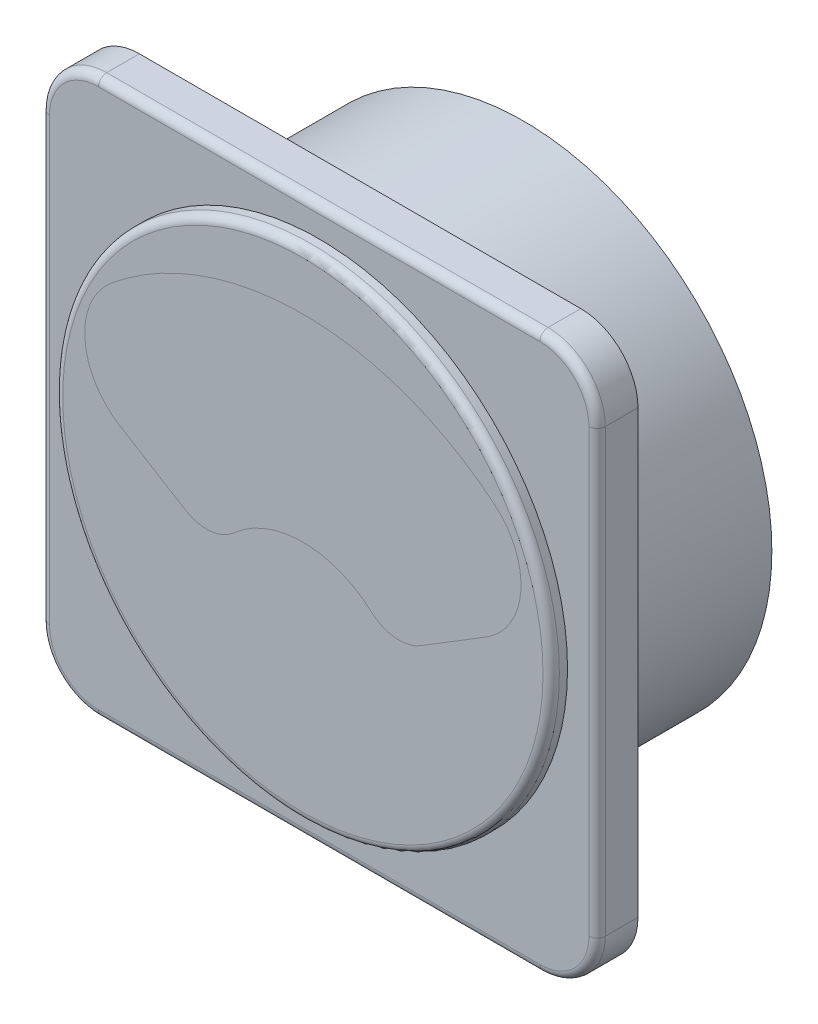
from build123d import *

# Parameters (mm, degrees)
SKETCH1_R           = 30.382618143
BOSS_EXTRUDE1_DEPTH = 20
SKETCH2_R           = 27.5
BOSS_EXTRUDE2_DEPTH = 5
SKETCH3_R           = 30.382618143
BOSS_EXTRUDE3_DEPTH = 2
BOSS_EXTRUDE4_DEPTH = 1
BOSS_EXTRUDE5_DEPTH = 1
FILLET1_R           = 1
FILLET2_R           = 1


with BuildPart() as part:
    # Sketch1 → Boss-Extrude1 (new body)
    with BuildSketch(Plane.XY):
        Circle(SKETCH1_R)
    extrude(amount=-BOSS_EXTRUDE1_DEPTH)


with BuildPart() as body_2:
    # Sketch2 → Boss-Extrude2 (new body)
    with BuildSketch(Plane.XY):
        with BuildLine():
            Line((-27, -34), (27, -34))
            ThreePointArc((27, -34), (31.949747468, -31.949747468), (34, -27))
            Line((34, -27), (34, 27))
            ThreePointArc((34, 27), (31.949747468, 31.949747468), (27, 34))
            Line((27, 34), (-27, 34))
            ThreePointArc((-27, 34), (-31.949747468, 31.949747468), (-34, 27))
            Line((-34, 27), (-34, -27))
            ThreePointArc((-34, -27), (-31.949747468, -31.949747468), (-27, -34))
        make_face()
        Circle(SKETCH2_R, mode=Mode.SUBTRACT)
    extrude(amount=BOSS_EXTRUDE2_DEPTH)

    # Fillet2
    fillet2_edges = [body_2.edges().sort_by_distance(p)[0] for p in [
        (-31.949747468, -31.949747468, 5),
        (0, -34, 5),
        (31.949747468, -31.949747468, 5),
        (34, 0, 5),
        (31.949747468, 31.949747468, 5),
        (0, 34, 5),
        (-31.949747468, 31.949747468, 5),
        (-34, 0, 5),
    ]]
    fillet(fillet2_edges, radius=FILLET2_R)


with BuildPart() as body_3:
    # Sketch3 → Boss-Extrude3 (new body)
    with BuildSketch(Plane.XY.offset(5)):
        Circle(SKETCH3_R)
        with BuildLine():
            Line((14.390861658, -4.518418841), (22.394682178, 0.392456244))
            ThreePointArc((22.394682178, 0.392456244), (26.6658507, 7.433621582), (23.419848559, 15.002264787))
            ThreePointArc((23.419848559, 15.002264787), (0, 23.42459846), (-23.419848559, 15.002264787))
            ThreePointArc((-23.419848559, 15.002264787), (-26.6658507, 7.433621582), (-22.394682178, 0.392456244))
            Line((-22.394682178, 0.392456244), (-14.390861658, -4.518418841))
            ThreePointArc((-14.390861658, -4.518418841), (-11.321097129, -5.235935812), (-8.432169686, -3.974039186))
            ThreePointArc((-8.432169686, -3.974039186), (0, -0.739608229), (8.432169686, -3.974039186))
            ThreePointArc((8.432169686, -3.974039186), (11.321097129, -5.235935812), (14.390861658, -4.518418841))
        make_face(mode=Mode.SUBTRACT)
    extrude(amount=BOSS_EXTRUDE3_DEPTH)

    # Fillet1
    fillet1_edges = [body_3.edges().sort_by_distance(p)[0] for p in [
        (-30.382618143, 0, 7),
    ]]
    fillet(fillet1_edges, radius=FILLET1_R)


with BuildPart() as body_4:
    # Sketch4 → Boss-Extrude4 (new body)
    with BuildSketch(Plane.XY):
        with BuildLine():
            Line((1.314265004, -6.854089459), (7.143315201, 19.166790622))
            ThreePointArc((7.143315201, 19.166790622), (6.991871463, 19.405673007), (6.752989077, 19.254229269))
            Line((6.752989077, 19.254229269), (0.92393888, -6.766650812))
            ThreePointArc((0.92393888, -6.766650812), (-1.705267873, -19.418356989), (1.314265004, -6.854089459))
        make_face()
    extrude(amount=BOSS_EXTRUDE4_DEPTH)


with BuildPart() as body_5:
    # Sketch5 → Boss-Extrude5 (new body)
    with BuildSketch(Plane.XY.offset(7)):
        with BuildLine():
            Line((14.390861658, -4.518418841), (22.394682178, 0.392456244))
            ThreePointArc((22.394682178, 0.392456244), (26.6658507, 7.433621582), (23.419848559, 15.002264787))
            ThreePointArc((23.419848559, 15.002264787), (0, 23.42459846), (-23.419848559, 15.002264787))
            ThreePointArc((-23.419848559, 15.002264787), (-26.6658507, 7.433621582), (-22.394682178, 0.392456244))
            Line((-22.394682178, 0.392456244), (-14.390861658, -4.518418841))
            ThreePointArc((-14.390861658, -4.518418841), (-11.321097129, -5.235935812), (-8.432169686, -3.974039186))
            ThreePointArc((-8.432169686, -3.974039186), (0, -0.739608229), (8.432169686, -3.974039186))
            ThreePointArc((8.432169686, -3.974039186), (11.321097129, -5.235935812), (14.390861658, -4.518418841))
        make_face()
    extrude(amount=-BOSS_EXTRUDE5_DEPTH)


solid = Compound([part.part, body_2.part, body_3.part, body_4.part, body_5.part])
